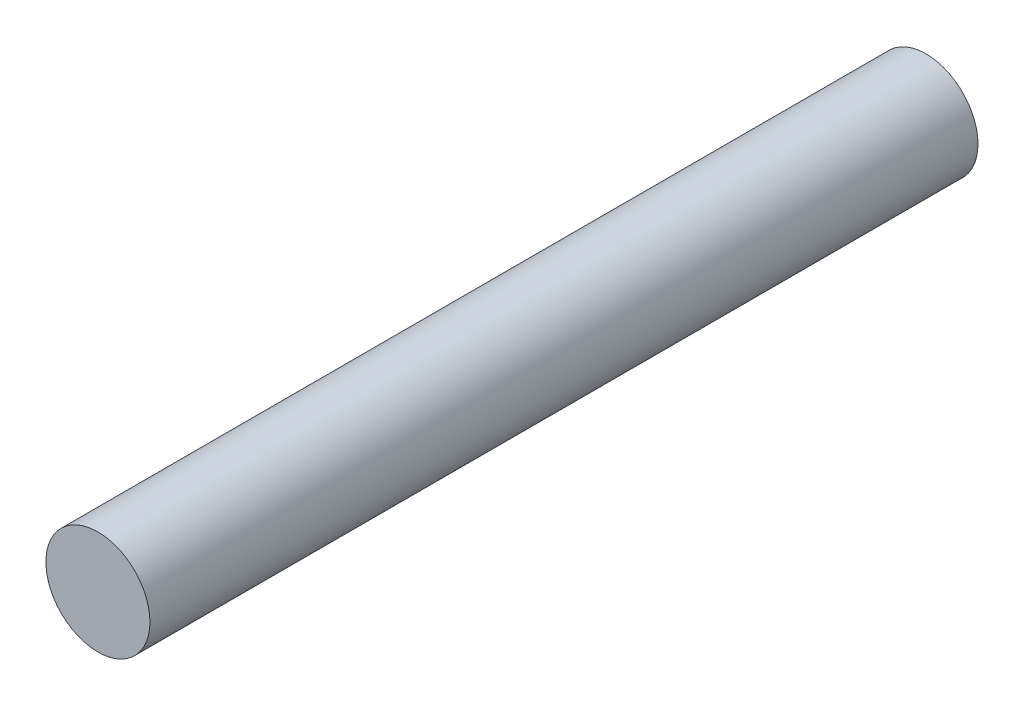
from build123d import *

# Parameters (mm, degrees)
SKETCH1_R           = 3.175
BOSS_EXTRUDE1_DEPTH = 50.52949


with BuildPart() as part:
    # Sketch1 → Boss-Extrude1 (new body)
    with BuildSketch(Plane.XY):
        Circle(SKETCH1_R)
    extrude(amount=BOSS_EXTRUDE1_DEPTH)


solid = part.part
